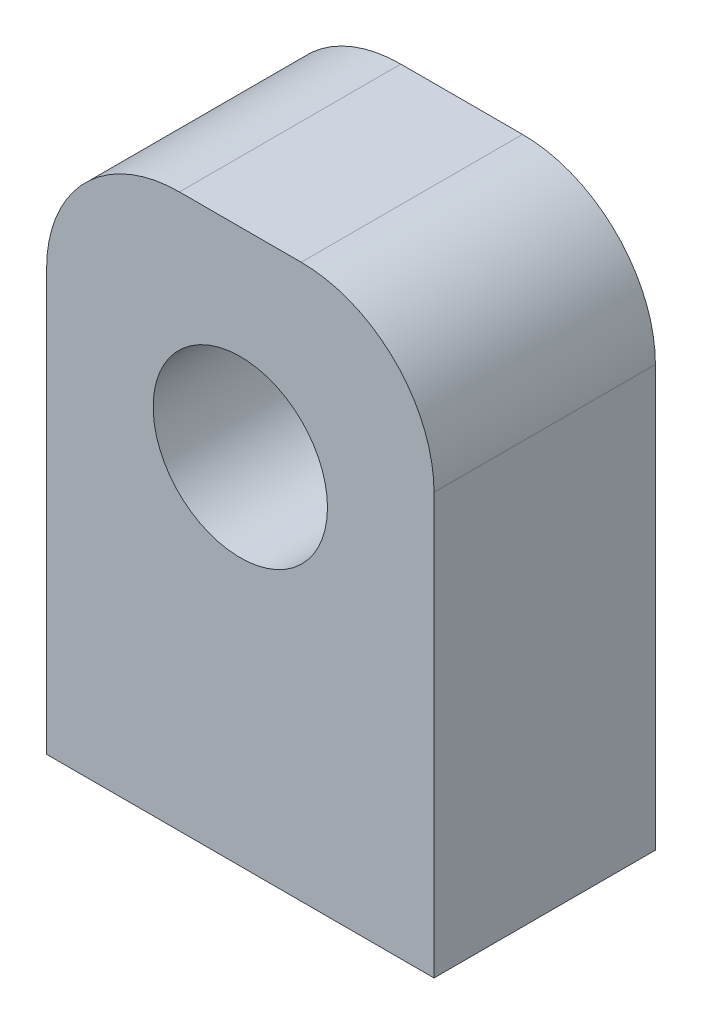
from build123d import *

# Parameters (mm, degrees)
SKETCH1_W           = 35
SKETCH1_H           = 20
BOSS_EXTRUDE1_DEPTH = 50
SKETCH2_R           = 7.875
CUT_EXTRUDE1_DEPTH  = 21
SKETCH3_R           = 1.75
CUT_EXTRUDE2_DEPTH  = 10
FILLET1_R           = 12


with BuildPart() as part:
    # Sketch1 → Boss-Extrude1 (new body)
    with BuildSketch(Plane(origin=(0, 0, 0), x_dir=(1, 0, 0), z_dir=(0, 1, 0))):
        with Locations((1.164675851, -0.855170824)):
            Rectangle(SKETCH1_W, SKETCH1_H)
    extrude(amount=BOSS_EXTRUDE1_DEPTH)

    # Sketch2 → Cut-Extrude1 (cut, through all)
    with BuildSketch(Plane.XY.offset(10.855170824)):
        with Locations((1.164675851, 32)):
            Circle(SKETCH2_R)
    extrude(amount=-CUT_EXTRUDE1_DEPTH, mode=Mode.SUBTRACT)

    # Sketch3 → Cut-Extrude2 (cut)
    with BuildSketch(Plane.XZ):
        with Locations((-8.335324149, 0.855170824)):
            Circle(SKETCH3_R)
        with Locations((10.664675851, 0.855170824)):
            Circle(SKETCH3_R)
    extrude(amount=-CUT_EXTRUDE2_DEPTH, mode=Mode.SUBTRACT)

    # Fillet1
    fillet1_edges = [part.edges().sort_by_distance(p)[0] for p in [
        (18.664675851, 50, 0.855170824),
        (-16.335324149, 50, 0.855170824),
    ]]
    fillet(fillet1_edges, radius=FILLET1_R)


solid = part.part
